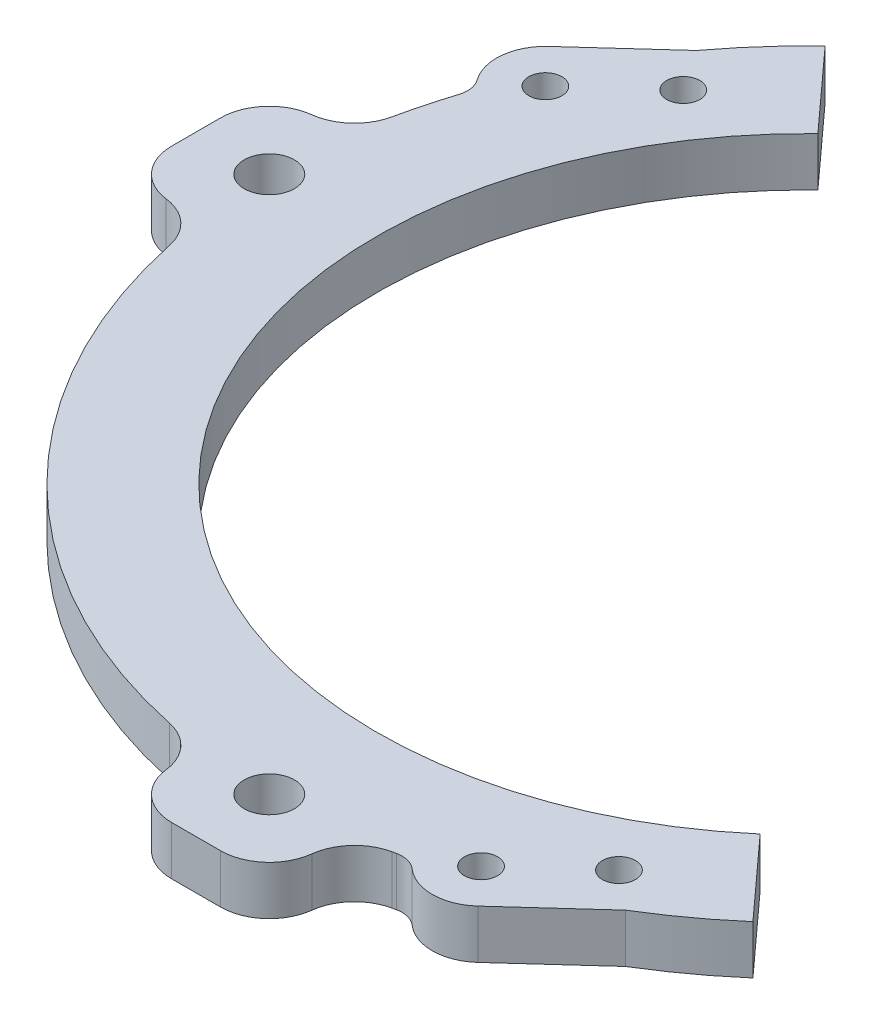
from build123d import *

# Parameters (mm, degrees)
SKETCH1_R                    = 69.85
SKETCH1_R_2                  = 55.88
BOSS_EXTRUDE1_DEPTH          = 6.35
BOSS_EXTRUDE2_DEPTH          = 6.35
FILLET1_R                    = 6.35
CIRPATTERN2_COUNT            = 4
FILLET1_OF_CIRPATTERN2_R     = 6.35
F_0_257_DIAMETER_HOLE1_D     = 6.5278
CIRPATTERN1_COUNT            = 4
SKETCH6_R                    = 3.2639
CUT_EXTRUDE1_DEPTH           = 7.3500001
BOSS_EXTRUDE4_DEPTH          = 6.35
FILLET3_R                    = 3.175
F_18_0_1695_DIAMETER_HOLE1_D = 4.3053


with BuildPart() as part:
    # Sketch1 → Boss-Extrude1 (new body)
    with BuildSketch(Plane(origin=(0, 0, 0), x_dir=(1, 0, 0), z_dir=(0, 1, 0))):
        Circle(SKETCH1_R)
        Circle(SKETCH1_R_2, mode=Mode.SUBTRACT)
    extrude(amount=BOSS_EXTRUDE1_DEPTH)

    # Sketch5 → Boss-Extrude2 (add)
    with BuildSketch(Plane(origin=(0, 6.35, 0), x_dir=(1, 0, 0), z_dir=(0, 1, 0))):
        with BuildLine():
            Line((-9.525, 63.5), (9.525, 63.5))
            Line((9.525, 63.5), (9.525, 73.025))
            ThreePointArc((9.525, 73.025), (7.665128061, 77.515128061), (3.175, 79.375))
            Line((3.175, 79.375), (-3.175, 79.375))
            ThreePointArc((-3.175, 79.375), (-7.665128061, 77.515128061), (-9.525, 73.025))
            Line((-9.525, 73.025), (-9.525, 63.5))
        make_face()
    boss_extrude2 = extrude(amount=-BOSS_EXTRUDE2_DEPTH)

    # Fillet1
    fillet1_edges = [part.edges().sort_by_distance(p)[0] for p in [
        (9.525, 3.175, -69.197520729),
        (-9.525, 3.175, -69.197520729),
    ]]
    fillet(fillet1_edges, radius=FILLET1_R)

    # CirPattern2: Boss-Extrude2 ×4 about axis
    cirpattern2_axis = Axis((0, 0, 0), (0, 1, 0))
    for i in range(1, CIRPATTERN2_COUNT):
        add(boss_extrude2.rotate(cirpattern2_axis, i * 360 / CIRPATTERN2_COUNT))

    # Fillet1 of CirPattern2
    fillet1_of_cirpattern2_edges = [part.edges().sort_by_distance(p)[0] for p in [
        (-69.197520729, 3.175, -9.525),
        (-69.197520729, 3.175, 9.525),
        (-9.525, 3.175, 69.197520729),
        (9.525, 3.175, 69.197520729),
        (69.197520729, 3.175, 9.525),
        (69.197520729, 3.175, -9.525),
    ]]
    fillet(fillet1_of_cirpattern2_edges, radius=FILLET1_OF_CIRPATTERN2_R)

    # F (0.257) Diameter Hole1 (through all)
    with Locations(Plane(origin=(0, 6.35, 0), x_dir=(1, 0, 0), z_dir=(0, 1, 0))):
        with Locations((69.85, 0)):
            f_0_257_diameter_hole1 = Hole(F_0_257_DIAMETER_HOLE1_D / 2)

    # CirPattern1: F (0.257) Diameter Hole1 ×4 about axis
    cirpattern1_axis = Axis((0, 0, 0), (0, 1, 0))
    for i in range(1, CIRPATTERN1_COUNT):
        add(f_0_257_diameter_hole1.rotate(cirpattern1_axis, i * 360 / CIRPATTERN1_COUNT), mode=Mode.SUBTRACT)

    # Sketch6 → Cut-Extrude1 (cut, through all)
    with BuildSketch(Plane.XZ):
        with BuildLine():
            Line((-38.749062578, -40.262694263), (-48.149496878, -50.60285022))
            ThreePointArc((-48.149496878, -50.60285022), (-46.98699519, -51.684086361), (-45.800220226, -52.738622728))
            Line((-45.800220226, -52.738622728), (-36.399785925, -42.398466772))
            ThreePointArc((-36.399785925, -42.398466772), (-37.589596152, -41.347269089), (-38.749062578, -40.262694263))
        make_face()
        with BuildLine():
            Line((-36.399785925, -42.398466772), (-45.800220226, -52.738622728))
            ThreePointArc((-45.800220226, -52.738622728), (-31.12686289, -62.531119506), (-14.468129908, -68.335171888))
            add(Edge.make_bspline(
                [(-14.468129908, -68.335171888), (-14.283432872, -68.374276505), (-14.099232, -68.420160929), (-13.915921077, -68.472867364), (-13.733896872, -68.532401891), (-13.553556281, -68.598733654), (-13.249844138, -68.723208999), (-13.125423196, -68.77795645), (-13.002168013, -68.83601258), (-12.88021375, -68.897344809), (-12.759693358, -68.961911786), (-12.355694209, -69.192010649), (-12.079622266, -69.372650227), (-11.814338628, -69.570883737), (-11.56151572, -69.78574391), (-11.322668236, -70.016027336), (-10.782274905, -70.606478562), (-10.496090022, -70.980818219), (-10.244386574, -71.379158998), (-10.029870298, -71.796677829), (-9.854233948, -72.228125174), (-9.660927551, -72.851945664), (-9.610789898, -73.037441883), (-9.567571656, -73.224014536), (-9.531268493, -73.411265552), (-9.501839293, -73.598800252), (-9.479207222, -73.786230121)],
                knots=[0, 0, 0, 0, 0, 0, 0, 0.147493178, 0.147493178, 0.147493178, 0.147493178, 0.147493178, 0.251288922, 0.251288922, 0.251288922, 0.251288922, 0.251288922, 0.500005624, 0.500005624, 0.500005624, 0.500005624, 0.500005624, 0.852506427, 0.852506427, 0.852506427, 0.852506427, 0.852506427, 1, 1, 1, 1, 1, 1, 1], degree=6))
            ThreePointArc((-9.479207222, -73.786230121), (-7.387403633, -77.776647676), (-3.175, -79.375))
            Line((-3.175, -79.375), (3.175, -79.375))
            ThreePointArc((3.175, -79.375), (7.387403633, -77.776647676), (9.479207222, -73.786230121))
            add(Edge.make_bspline(
                [(14.468129908, -68.335171888), (14.283432872, -68.374276505), (14.099232, -68.420160929), (13.915921077, -68.472867364), (13.733896872, -68.532401891), (13.553556281, -68.598733654), (13.249844138, -68.723208999), (13.125423196, -68.77795645), (13.002168013, -68.83601258), (12.88021375, -68.897344809), (12.759693358, -68.961911786), (12.355694209, -69.192010649), (12.079622266, -69.372650227), (11.814338628, -69.570883737), (11.56151572, -69.78574391), (11.322668236, -70.016027336), (10.782274905, -70.606478562), (10.496090022, -70.980818219), (10.244386574, -71.379158998), (10.029870298, -71.796677829), (9.854233948, -72.228125174), (9.660927551, -72.851945664), (9.610789898, -73.037441883), (9.567571656, -73.224014536), (9.531268493, -73.411265552), (9.501839293, -73.598800252), (9.479207222, -73.786230121)],
                knots=[0, 0, 0, 0, 0, 0, 0, 0.147493178, 0.147493178, 0.147493178, 0.147493178, 0.147493178, 0.251288922, 0.251288922, 0.251288922, 0.251288922, 0.251288922, 0.500005624, 0.500005624, 0.500005624, 0.500005624, 0.500005624, 0.852506427, 0.852506427, 0.852506427, 0.852506427, 0.852506427, 1, 1, 1, 1, 1, 1, 1], degree=6))
            ThreePointArc((14.468129908, -68.335171888), (49.391408666, -49.391408666), (68.335171888, -14.468129908))
            add(Edge.make_bspline(
                [(68.335171888, -14.468129908), (68.374276505, -14.283432872), (68.420160929, -14.099232), (68.472867364, -13.915921077), (68.532401891, -13.733896872), (68.598733654, -13.553556281), (68.846403967, -12.949256038), (69.059475497, -12.535015212), (69.310044177, -12.138083802), (69.595960031, -11.763541247), (69.914101744, -11.415952673), (70.50455297, -10.875559342), (70.762813807, -10.667280882), (71.033632627, -10.475600201), (71.315394329, -10.301582166), (71.606347562, -10.146042489), (72.029097801, -9.952540464), (72.154851861, -9.898875057), (72.281748365, -9.84855844), (72.409651228, -9.801620057), (72.53842294, -9.758080416), (72.851945664, -9.660927551), (73.037441883, -9.610789898), (73.224014536, -9.567571656), (73.411265552, -9.531268493), (73.598800252, -9.501839293), (73.786230121, -9.479207222)],
                knots=[0, 0, 0, 0, 0, 0, 0, 0.147493573, 0.147493573, 0.147493573, 0.147493573, 0.147493573, 0.499994376, 0.499994376, 0.499994376, 0.499994376, 0.499994376, 0.748711078, 0.748711078, 0.748711078, 0.748711078, 0.748711078, 0.852506822, 0.852506822, 0.852506822, 0.852506822, 0.852506822, 1, 1, 1, 1, 1, 1, 1], degree=6))
            ThreePointArc((73.786230121, -9.479207222), (77.776647676, -7.387403633), (79.375, -3.175))
            Line((79.375, -3.175), (79.375, 3.175))
            ThreePointArc((79.375, 3.175), (77.776647676, 7.387403633), (73.786230121, 9.479207222))
            add(Edge.make_bspline(
                [(68.335171888, 14.468129908), (68.374276505, 14.283432872), (68.420160929, 14.099232), (68.472867364, 13.915921077), (68.532401891, 13.733896872), (68.598733654, 13.553556281), (68.846403967, 12.949256038), (69.059475497, 12.535015212), (69.310044177, 12.138083802), (69.595960031, 11.763541247), (69.914101744, 11.415952673), (70.50455297, 10.875559342), (70.762813807, 10.667280882), (71.033632627, 10.475600201), (71.315394329, 10.301582166), (71.606347562, 10.146042489), (72.029097801, 9.952540464), (72.154851861, 9.898875057), (72.281748365, 9.84855844), (72.409651228, 9.801620057), (72.53842294, 9.758080416), (72.851945664, 9.660927551), (73.037441883, 9.610789898), (73.224014536, 9.567571656), (73.411265552, 9.531268493), (73.598800252, 9.501839293), (73.786230121, 9.479207222)],
                knots=[0, 0, 0, 0, 0, 0, 0, 0.147493573, 0.147493573, 0.147493573, 0.147493573, 0.147493573, 0.499994376, 0.499994376, 0.499994376, 0.499994376, 0.499994376, 0.748711078, 0.748711078, 0.748711078, 0.748711078, 0.748711078, 0.852506822, 0.852506822, 0.852506822, 0.852506822, 0.852506822, 1, 1, 1, 1, 1, 1, 1], degree=6))
            ThreePointArc((68.335171888, 14.468129908), (60.980316639, 34.064989103), (48.149496878, 50.60285022))
            Line((48.149496878, 50.60285022), (38.749062578, 40.262694263))
            ThreePointArc((38.749062578, 40.262694263), (51.419218279, 21.877805913), (55.88, 0))
            ThreePointArc((55.88, 0), (23.329748847, -50.776935894), (-36.399785925, -42.398466772))
        make_face()
        with Locations((0, -69.85)):
            Circle(SKETCH6_R, mode=Mode.SUBTRACT)
        with Locations((69.85, 0)):
            Circle(SKETCH6_R, mode=Mode.SUBTRACT)
        with BuildLine():
            Line((45.800220226, 52.738622728), (36.399785925, 42.398466772))
            ThreePointArc((36.399785925, 42.398466772), (37.589596152, 41.347269089), (38.749062578, 40.262694263))
            Line((38.749062578, 40.262694263), (48.149496878, 50.60285022))
            ThreePointArc((48.149496878, 50.60285022), (46.98699519, 51.684086361), (45.800220226, 52.738622728))
        make_face()
    extrude(amount=-CUT_EXTRUDE1_DEPTH, mode=Mode.SUBTRACT)

    # Sketch8 → Boss-Extrude4 (add)
    with BuildSketch(Plane(origin=(0, 0, 0), x_dir=(-1, 0, 0), z_dir=(0, -1, 0))):
        with BuildLine():
            Line((47.292152613, 49.659800874), (38.749062578, 40.262694263))
            Line((38.749062578, 40.262694263), (62.241829106, 18.904969177))
            Line((62.241829106, 18.904969177), (66.513374123, 23.603522482))
            ThreePointArc((66.513374123, 23.603522482), (68.15763817, 28.177007956), (66.086365835, 32.573620805))
            Line((66.086365835, 32.573620805), (47.292152613, 49.659800874))
        make_face()
        with BuildLine():
            Line((-36.399785925, -42.398466772), (-44.94287596, -51.795573383))
            Line((-44.94287596, -51.795573383), (-26.148662738, -68.881753452))
            ThreePointArc((-26.148662738, -68.881753452), (-21.575177264, -70.526017499), (-17.178564415, -68.454745164))
            Line((-17.178564415, -68.454745164), (-12.907019398, -63.756191858))
            Line((-12.907019398, -63.756191858), (-36.399785925, -42.398466772))
        make_face()
    extrude(amount=-BOSS_EXTRUDE4_DEPTH)

    # Fillet3
    fillet3_edges = [part.edges().sort_by_distance(p)[0] for p in [
        (-65.95747234, 3.175, -22.992049549),
        (16.622662632, 3.175, 67.843272231),
    ]]
    fillet(fillet3_edges, radius=FILLET3_R)

    # #18 (0.1695) Diameter Hole1 (through all)
    with Locations(Plane(origin=(0, 0, 0), x_dir=(-1, 0, 0), z_dir=(0, -1, 0))):
        with Locations((61.814820818, 27.875067499), (52.417714206, 36.418157534)):
            f_18_0_1695_diameter_hole1 = Hole(F_18_0_1695_DIAMETER_HOLE1_D / 2)

    # Mirror8: #18 (0.1695) Diameter Hole1 across plane
    add(f_18_0_1695_diameter_hole1.mirror(Plane(origin=(0, 0, 0), x_dir=(-0.739929654, 0, 0.672684255), z_dir=(-0.672684255, 0, -0.739929654))), mode=Mode.SUBTRACT)


solid = part.part
